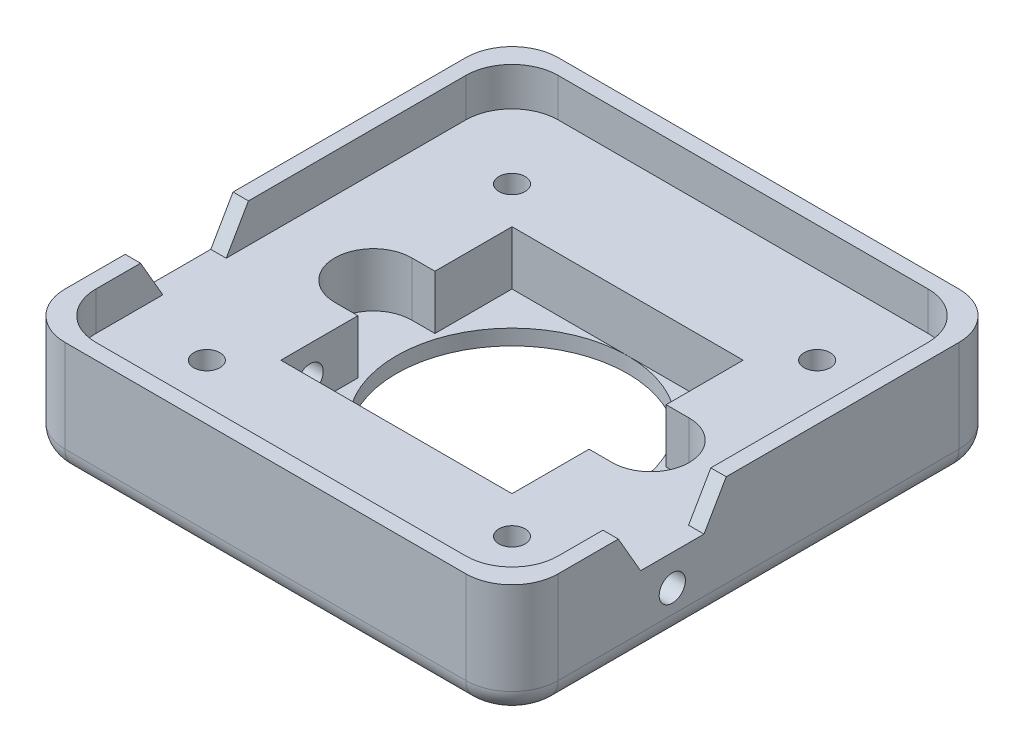
from build123d import *

# Parameters (mm, degrees)
SKETCH_1_W               = 32
SKETCH_1_H               = 32
SKETCH_1_R               = 7.5
EXTRUDE_1_DEPTH          = 5
CUT_EXTRUDE_1_DEPTH      = 3.5
SKETCH_3_W               = 32
SKETCH_3_H               = 32
SKETCH_3_W_2             = 30
SKETCH_3_H_2             = 30
EXTRUDE_2_DEPTH          = 2.5
SKETCH_4_R               = 0.85
CUT_EXTRUDE_2_DEPTH      = 8.5
SKETCH_5_R               = 9
CUT_EXTRUDE_3_DEPTH      = 0.5
FILLET_1_R               = 3
SKETCH_6_R               = 0.85
CUT_EXTRUDE_4_DEPTH      = 17
CUT_EXTRUDE_4_DEPTH_BACK = 17
FILLET_2_R               = 1.5


with BuildPart() as part:
    # 草图1 → 凸台-拉伸1 (new body)
    with BuildSketch(Plane(origin=(0, 0, 0), x_dir=(1, 0, 0), z_dir=(0, 1, 0))):
        Rectangle(SKETCH_1_W, SKETCH_1_H)
        with Locations(Location((0, 0, 0), (0, 0, 270))):  # turned: the seam where the file's is
            Circle(SKETCH_1_R, mode=Mode.SUBTRACT)
    extrude(amount=EXTRUDE_1_DEPTH)

    # 草图2 → 切除-拉伸1 (cut)
    with BuildSketch(Plane(origin=(0, 5, 0), x_dir=(1, 0, 0), z_dir=(0, 1, 0))):
        with BuildLine():
            Line((-1.6e-08, 7.5), (-7.5, 7.5))
            Line((-7.5, 7.5), (-7.5, 2.5))
            Line((-7.5, 2.5), (-7.071067812, 2.5))
            ThreePointArc((-7.071067812, 2.5), (-4.330127025, 6.123724352), (-1.6e-08, 7.5))
        make_face()
        with BuildLine():
            Line((7.5, 7.5), (-1.6e-08, 7.5))
            ThreePointArc((-1.6e-08, 7.5), (4.330127013, 6.123724361), (7.071067812, 2.5))
            Line((7.071067812, 2.5), (7.5, 2.5))
            Line((7.5, 2.5), (7.5, 7.5))
        make_face()
        with BuildLine():
            Line((-7.071067812, 2.5), (-7.5, 2.5))
            Line((-7.5, 2.5), (-9, 2.5))
            ThreePointArc((-9, 2.5), (-11.5, 0), (-9, -2.5))
            Line((-9, -2.5), (-7.5, -2.5))
            Line((-7.5, -2.5), (-7.071067812, -2.5))
            ThreePointArc((-7.071067812, -2.5), (-7.5, 0), (-7.071067812, 2.5))
        make_face()
        with BuildLine():
            Line((7.5, 2.5), (7.071067812, 2.5))
            ThreePointArc((7.071067812, 2.5), (7.391989197, 1.26826484), (7.5, 0))
            ThreePointArc((7.5, 0), (7.391989197, -1.26826484), (7.071067812, -2.5))
            Line((7.071067812, -2.5), (7.5, -2.5))
            Line((7.5, -2.5), (9, -2.5))
            ThreePointArc((9, -2.5), (11.5, 0), (9, 2.5))
            Line((9, 2.5), (7.5, 2.5))
        make_face()
        with BuildLine():
            Line((7.5, -2.5), (7.071067812, -2.5))
            ThreePointArc((7.071067812, -2.5), (4.330127019, -6.123724357), (0, -7.5))
            Line((0, -7.5), (7.5, -7.5))
            Line((7.5, -7.5), (7.5, -2.5))
        make_face()
        with BuildLine():
            ThreePointArc((0, -7.5), (-4.330127019, -6.123724357), (-7.071067812, -2.5))
            Line((-7.071067812, -2.5), (-7.5, -2.5))
            Line((-7.5, -2.5), (-7.5, -7.5))
            Line((-7.5, -7.5), (0, -7.5))
        make_face()
    extrude(amount=-CUT_EXTRUDE_1_DEPTH, mode=Mode.SUBTRACT)

    # 草图3 → 凸台-拉伸2 (add)
    with BuildSketch(Plane(origin=(0, 5, 0), x_dir=(1, 0, 0), z_dir=(0, 1, 0))):
        Rectangle(SKETCH_3_W, SKETCH_3_H)
        Rectangle(SKETCH_3_W_2, SKETCH_3_H_2, mode=Mode.SUBTRACT)
    extrude(amount=EXTRUDE_2_DEPTH)

    # 草图4 → 切除-拉伸2 (cut, through all)
    with BuildSketch(Plane.XZ):
        with Locations(Location((-9.899494937, 9.899494937, 0), (0, 0, 270))):  # turned: the seam where the file's is
            Circle(SKETCH_4_R)
        with Locations(Location((9.899494937, 9.899494937, 0), (0, 0, 270))):  # turned: the seam where the file's is
            Circle(SKETCH_4_R)
        with Locations(Location((9.899494937, -9.899494937, 0), (0, 0, 270))):  # turned: the seam where the file's is
            Circle(SKETCH_4_R)
        with Locations(Location((-9.899494937, -9.899494937, 0), (0, 0, 270))):  # turned: the seam where the file's is
            Circle(SKETCH_4_R)
    extrude(amount=-CUT_EXTRUDE_2_DEPTH, mode=Mode.SUBTRACT)

    # 草图5 → 切除-拉伸3 (cut)
    with BuildSketch(Plane.XZ):
        with Locations(Location((0, 0, 0), (0, 0, 270))):  # turned: the seam where the file's is
            Circle(SKETCH_5_R)
    extrude(amount=-CUT_EXTRUDE_3_DEPTH, mode=Mode.SUBTRACT)

    # 圆角1
    fillet_1_edges = [part.edges().sort_by_distance(p)[0] for p in [
        (15, 6.25, -15),
        (-15, 6.25, -15),
        (-15, 6.25, 15),
        (15, 6.25, 15),
        (-16, 3.75, -16),
        (16, 3.75, -16),
        (16, 3.75, 16),
        (-16, 3.75, 16),
    ]]
    fillet(fillet_1_edges, radius=FILLET_1_R)

    # 草图6 → 切除-拉伸4 (cut, two sides)
    with BuildSketch(Plane(origin=(0, 0, 0), x_dir=(0, 0, -1), z_dir=(1, 0, 0))) as cut_extrude_4_sk:
        with Locations((-5.6, 3)):
            Circle(SKETCH_6_R)
        Polygon((-7.656624327, 5), (-3.543375673, 5), (-2.1, 7.5), (-9.1, 7.5), align=None)
    extrude(amount=CUT_EXTRUDE_4_DEPTH, mode=Mode.SUBTRACT)
    extrude(cut_extrude_4_sk.sketch, amount=-CUT_EXTRUDE_4_DEPTH_BACK, mode=Mode.SUBTRACT)

    # 圆角2
    fillet_2_edges = [part.edges().sort_by_distance(p)[0] for p in [
        (-16, 0, 0),
        (0, 0, -16),
        (16, 0, 0),
        (0, 0, 16),
        (-15.121320344, 0, 15.121320344),
        (15.121320344, 0, 15.121320344),
        (15.121320344, 0, -15.121320344),
        (-15.121320344, 0, -15.121320344),
    ]]
    fillet(fillet_2_edges, radius=FILLET_2_R)


solid = part.part
